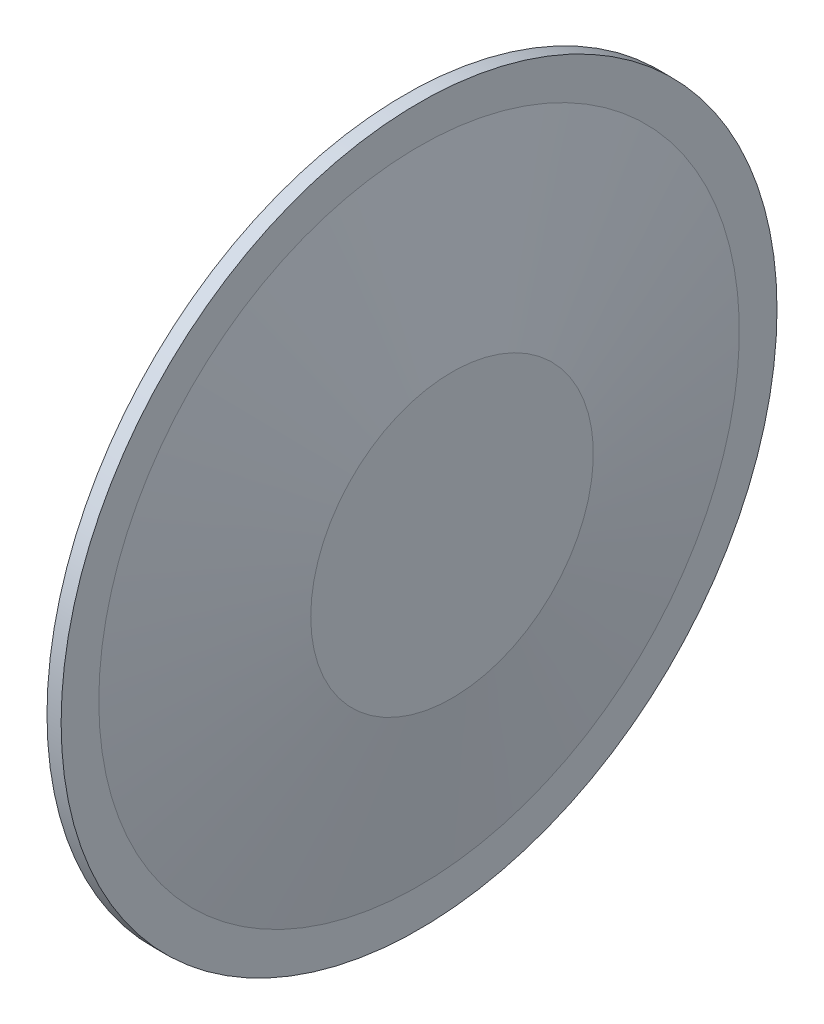
from build123d import *

# Parameters (mm, degrees)
AUFSATZ_LINEAR_START            = 3.5
SKIZZE2_R                       = 1.575
AUFSATZ_LINEAR_AUSTRAGEN1_DEPTH = 9
VERRUNDUNG1_R                   = 1
VERRUNDUNG2_R                   = 2.5


with BuildPart() as part:
    # Skizze1 → Rotation1 (revolve)
    with BuildSketch(Plane.XY):
        Polygon((0, 33.862994677), (0, 38), (1.5, 38), (1.5, 34), (5, 15), (5, 0), (3.5, 0), (3.5, 14.862994677), align=None)
    revolve(axis=Axis((0, 0, 0), (1, 0, 0)))

    # Skizze2 → Aufsatz-Linear austragen1 (add)
    with BuildSketch(Plane(origin=(0, 0, 0), x_dir=(0, 0, -1), z_dir=(1, 0, 0)).offset(AUFSATZ_LINEAR_START)):
        with Locations((9.525, 0)):
            Circle(SKIZZE2_R)
        with Locations((-9.525, 0)):
            Circle(SKIZZE2_R)
    extrude(amount=-AUFSATZ_LINEAR_AUSTRAGEN1_DEPTH)

    # Verrundung1
    verrundung1_edges = [part.edges().sort_by_distance(p)[0] for p in [
        (-5.5, 0, -7.95),
        (-5.5, 0, 11.1),
    ]]
    fillet(verrundung1_edges, radius=VERRUNDUNG1_R)

    # Verrundung2
    verrundung2_edges = [part.edges().sort_by_distance(p)[0] for p in [
        (3.5, 0, -7.95),
        (3.5, 0, 11.1),
    ]]
    fillet(verrundung2_edges, radius=VERRUNDUNG2_R)


solid = part.part
